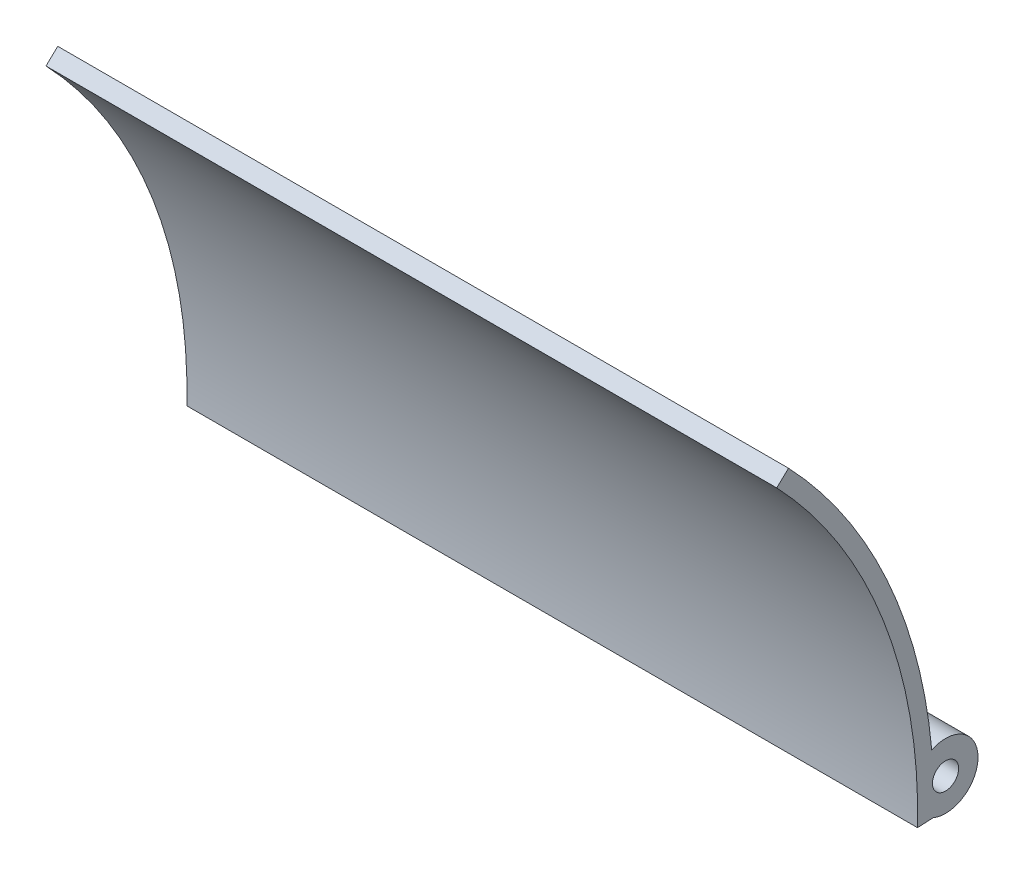
from build123d import *

# Parameters (mm, degrees)
SKETCH1_R           = 3.225
BOSS_EXTRUDE1_DEPTH = 180


with BuildPart() as part:
    # Sketch1 → Boss-Extrude1 (new body)
    with BuildSketch(Plane(origin=(0, 0, 0), x_dir=(0, 0, -1), z_dir=(1, 0, 0))):
        with BuildLine():
            Line((91.08739178, 86.768237615), (93.983652249, 89.527164089))
            ThreePointArc((93.983652249, 89.527164089), (118.199696764, 53.636477187), (129.264525293, 11.778051656))
            ThreePointArc((129.264525293, 11.778051656), (140.662275505, 4.728846729), (129.616513334, -2.860035801))
            Line((129.616513334, -2.860035801), (125.762921617, -3.054103199))
            ThreePointArc((125.762921617, -3.054103199), (117.358543926, 45.305763073), (91.08739178, 86.768237615))
        make_face()
        with Locations((132.664587351, 4.536533997)):
            Circle(SKETCH1_R, mode=Mode.SUBTRACT)
    extrude(amount=BOSS_EXTRUDE1_DEPTH)


solid = part.part
